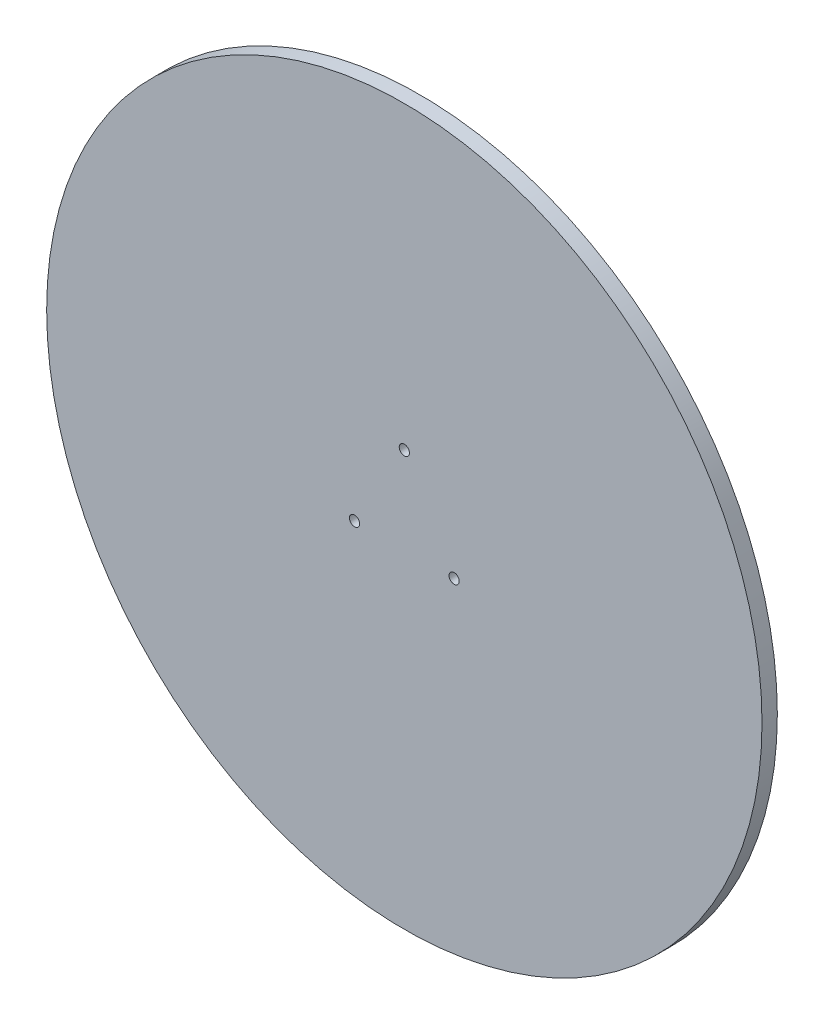
from build123d import *

# Parameters (mm, degrees)
SKETCH1_R           = 140
SKETCH1_R_2         = 2
BOSS_EXTRUDE1_DEPTH = 6


with BuildPart() as part:
    # Sketch1 → Boss-Extrude1 (new body)
    with BuildSketch(Plane.XY):
        Circle(SKETCH1_R)
        with Locations((0, 22.5)):
            Circle(SKETCH1_R_2, mode=Mode.SUBTRACT)
        with Locations((19.485571585, -11.25)):
            Circle(SKETCH1_R_2, mode=Mode.SUBTRACT)
        with Locations((-19.485571585, -11.25)):
            Circle(SKETCH1_R_2, mode=Mode.SUBTRACT)
    extrude(amount=BOSS_EXTRUDE1_DEPTH)


solid = part.part
